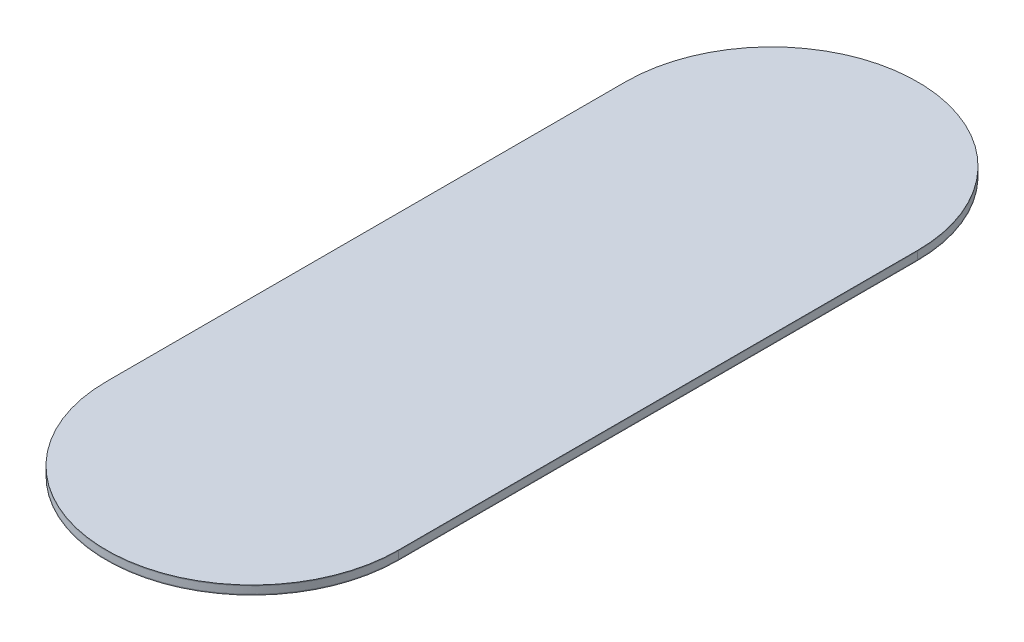
from build123d import *

# Parameters (mm, degrees)
BOSS_EXTRUDE1_DEPTH = 0.25
BOSS_EXTRUDE6_DEPTH = 2.5
BOSS_EXTRUDE7_DEPTH = 0.25


with BuildPart() as part:
    # Sketch1 → Boss-Extrude1 (new body)
    with BuildSketch(Plane(origin=(0, 0, 0), x_dir=(1, 0, 0), z_dir=(0, 1, 0))):
        with BuildLine():
            Line((50, 88.9), (50, -88.9))
            ThreePointArc((50, -88.9), (0, -138.9), (-50, -88.9))
            Line((-50, -88.9), (-50, 88.9))
            ThreePointArc((-50, 88.9), (0, 138.9), (50, 88.9))
        make_face()
    extrude(amount=BOSS_EXTRUDE1_DEPTH)


with BuildPart() as body_2:
    # Sketch5 → Boss-Extrude6 (new body)
    with BuildSketch(Plane(origin=(0, 0.25, 0), x_dir=(1, 0, 0), z_dir=(0, 1, 0))):
        with BuildLine():
            Line((-50, 88.9), (-50, -88.9))
            ThreePointArc((-50, -88.9), (0, -138.9), (50, -88.9))
            Line((50, -88.9), (50, 88.9))
            ThreePointArc((50, 88.9), (0, 138.9), (-50, 88.9))
        make_face()
    extrude(amount=BOSS_EXTRUDE6_DEPTH)


with BuildPart() as body_3:
    # Sketch6 → Boss-Extrude7 (new body)
    with BuildSketch(Plane(origin=(0, 2.75, 0), x_dir=(1, 0, 0), z_dir=(0, 1, 0))):
        with BuildLine():
            Line((-50, 88.9), (-50, -88.9))
            ThreePointArc((-50, -88.9), (0, -138.9), (50, -88.9))
            Line((50, -88.9), (50, 88.9))
            ThreePointArc((50, 88.9), (0, 138.9), (-50, 88.9))
        make_face()
    extrude(amount=BOSS_EXTRUDE7_DEPTH)


solid = Compound([part.part, body_2.part, body_3.part])
